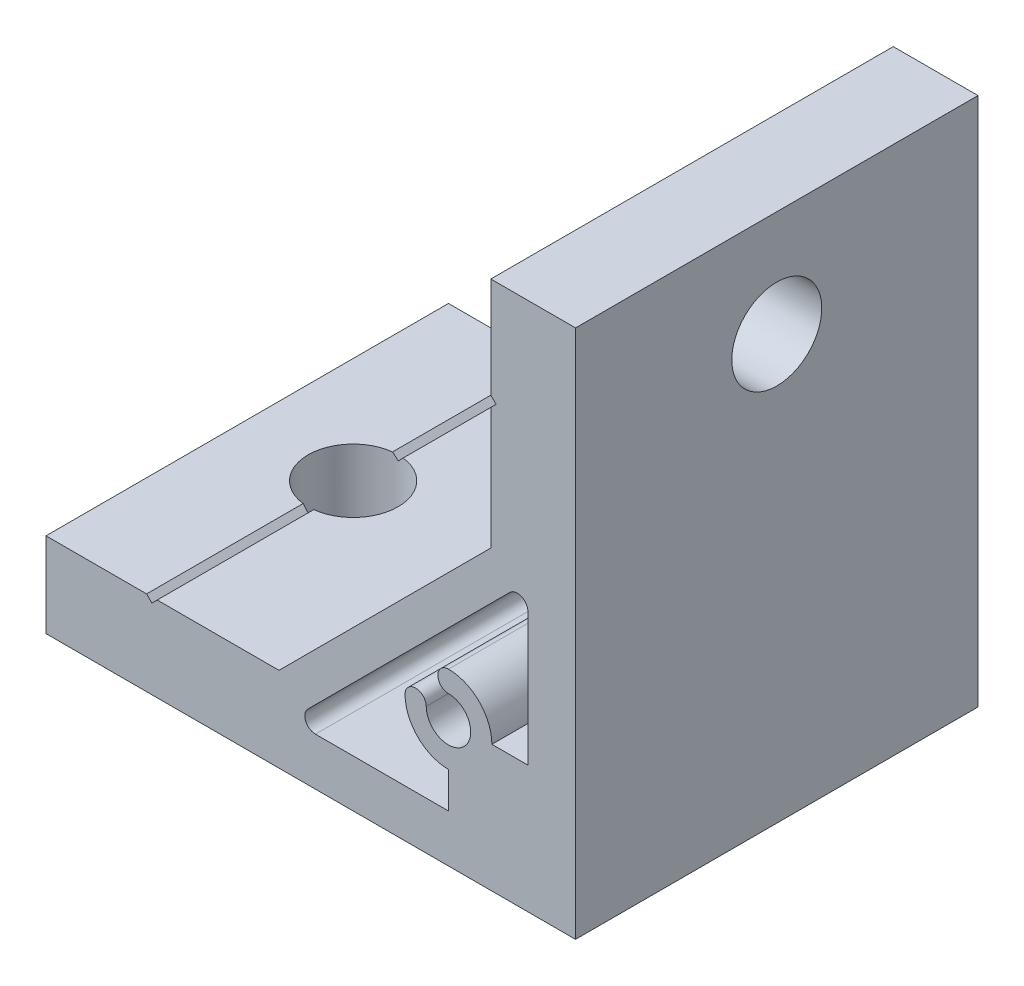
from build123d import *

# Parameters (mm, degrees)
EXTRUDE_1_DEPTH     = 19
SKETCH_2_R          = 4.25
CUT_EXTRUDE_1_DEPTH = 9
SKETCH_3_R          = 4.25
CUT_EXTRUDE_2_DEPTH = 9


with BuildPart() as part:
    # Эскиз1 → Бобышка-Вытянуть1 (new body, symmetric)
    with BuildSketch(Plane.XY):
        Polygon((-50, 0), (0, 0), (0, 50), (-8, 50), (-8, 40.5), (-7.5, 40), (-8, 39.5), (-8, 28), (-28, 8), (-39.5, 8), (-40, 7.5), (-40.5, 8), (-50, 8), align=None)
        with BuildLine():
            Line((-4.5, 12), (-4.5, 24.560303038))
            ThreePointArc((-4.5, 24.560303038), (-5.117316568, 25.484182571), (-6.207106781, 25.267409819))
            Line((-6.207106781, 25.267409819), (-25.267409819, 6.207106781))
            ThreePointArc((-25.267409819, 6.207106781), (-25.484182571, 5.117316568), (-24.560303038, 4.5))
            Line((-24.560303038, 4.5), (-12, 4.5))
            Line((-12, 4.5), (-12, 7.9))
            ThreePointArc((-12, 7.9), (-14.899137803, 9.100862197), (-16.1, 12))
            ThreePointArc((-16.1, 12), (-15.1, 13), (-14.1, 12))
            ThreePointArc((-14.1, 12), (-10.51507576, 10.51507576), (-12, 14.1))
            ThreePointArc((-12, 14.1), (-13, 15.1), (-12, 16.1))
            ThreePointArc((-12, 16.1), (-9.100862197, 14.899137803), (-7.9, 12))
            Line((-7.9, 12), (-4.5, 12))
        make_face(mode=Mode.SUBTRACT)
    extrude(amount=EXTRUDE_1_DEPTH, both=True)

    # Эскиз2 → Вырез-Вытянуть1 (cut, through all)
    with BuildSketch(Plane.ZY.offset(8)):
        with Locations(Location((0, 40, 0), (0, 0, 270))):  # turned: the seam where the file's is
            Circle(SKETCH_2_R)
    extrude(amount=-CUT_EXTRUDE_1_DEPTH, mode=Mode.SUBTRACT)

    # Эскиз3 → Вырез-Вытянуть2 (cut, through all)
    with BuildSketch(Plane(origin=(0, 8, 0), x_dir=(1, 0, 0), z_dir=(0, 1, 0))):
        with Locations(Location((-40, 0, 0), (0, 0, 180))):  # turned: the seam where the file's is
            Circle(SKETCH_3_R)
    extrude(amount=-CUT_EXTRUDE_2_DEPTH, mode=Mode.SUBTRACT)


solid = part.part
